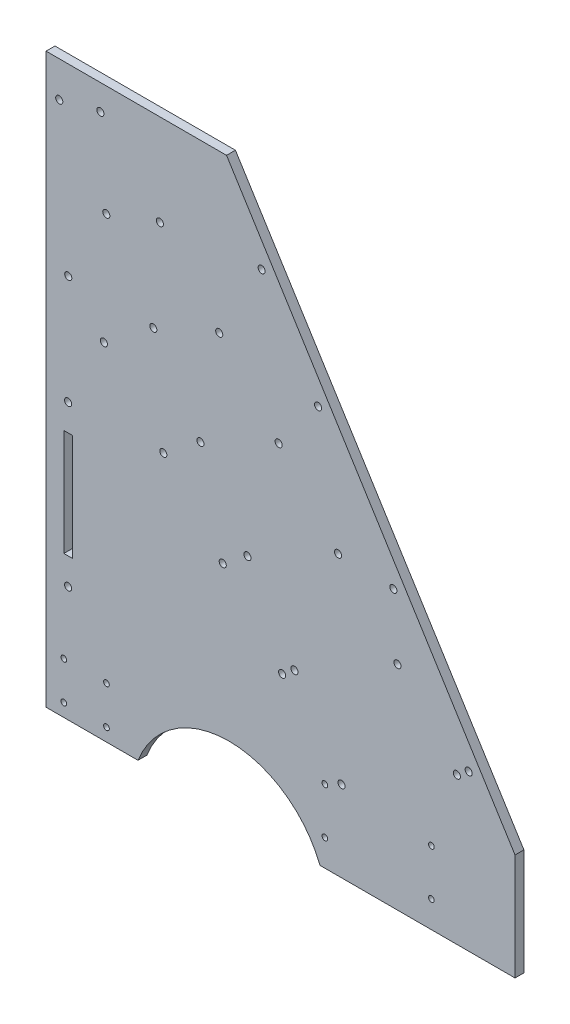
from build123d import *

# Parameters (mm, degrees)
SKETCH1_W           = 381.36114963
SKETCH1_H           = 320
BOSS_EXTRUDE1_DEPTH = 5
SKETCH2_R           = 55
CUT_EXTRUDE1_DEPTH  = 5
CUT_EXTRUDE2_DEPTH  = 5
SKETCH6_R           = 1.6
CUT_EXTRUDE5_DEPTH  = 5
CUT_EXTRUDE6_DEPTH  = 10
SKETCH4_R           = 1.6
CUT_EXTRUDE7_DEPTH  = 10
CUT_EXTRUDE8_DEPTH  = 31.5
SKETCH9_R           = 2
CUT_EXTRUDE9_DEPTH  = 10
CUT_EXTRUDE10_DEPTH = 10
CUT_EXTRUDE11_DEPTH = 10
SKETCH14_W          = 4.8
SKETCH14_H          = 60
CUT_EXTRUDE12_DEPTH = 5
SKETCH15_R          = 2
CUT_EXTRUDE13_DEPTH = 5


with BuildPart() as part:
    # Sketch1 → Boss-Extrude1 (new body)
    with BuildSketch(Plane.XY):
        with Locations((190.680574815, 160)):
            Rectangle(SKETCH1_W, SKETCH1_H)
    extrude(amount=BOSS_EXTRUDE1_DEPTH)

    # Sketch2 → Cut-Extrude1 (cut)
    with BuildSketch(Plane.XY.offset(5)):
        with Locations((103, -20)):
            Circle(SKETCH2_R)
    extrude(amount=-CUT_EXTRUDE1_DEPTH, mode=Mode.SUBTRACT)

    # Sketch3 → Cut-Extrude2 (cut)
    with BuildSketch(Plane.XY.offset(5)):
        with BuildLine():
            ThreePointArc((120.330565639, 275.917926616), (119.694307975, 273.161991895), (122.450242696, 272.525734232))
            Line((122.450242696, 272.525734232), (120.330565639, 275.917926616))
        make_face()
        with BuildLine():
            Line((120.330565639, 275.917926616), (122.450242696, 272.525734232))
            ThreePointArc((122.450242696, 272.525734232), (123.139643582, 273.252211183), (123.390404167, 274.221830424))
            ThreePointArc((123.390404167, 274.221830424), (122.360023408, 275.971069838), (120.330565639, 275.917926616))
        make_face()
        with BuildLine():
            ThreePointArc((152.125721493, 225.035040847), (151.489463829, 222.279106126), (154.24539855, 221.642848462))
            Line((154.24539855, 221.642848462), (152.125721493, 225.035040847))
        make_face()
        with BuildLine():
            Line((152.125721493, 225.035040847), (154.24539855, 221.642848462))
            ThreePointArc((154.24539855, 221.642848462), (154.934799436, 222.369325414), (155.185560021, 223.338944654))
            ThreePointArc((155.185560021, 223.338944654), (154.155179262, 225.088184069), (152.125721493, 225.035040847))
        make_face()
        with BuildLine():
            ThreePointArc((194.519262632, 157.191193154), (193.883004968, 154.435258433), (196.638939688, 153.79900077))
            Line((196.638939688, 153.79900077), (194.519262632, 157.191193154))
        make_face()
        with BuildLine():
            Line((194.519262632, 157.191193154), (196.638939688, 153.79900077))
            ThreePointArc((196.638939688, 153.79900077), (197.328340574, 154.525477721), (197.57910116, 155.495096962))
            ThreePointArc((197.57910116, 155.495096962), (196.5487204, 157.244336376), (194.519262632, 157.191193154))
        make_face()
        with BuildLine():
            ThreePointArc((236.91280377, 89.347345462), (236.276546106, 86.591410741), (239.032480827, 85.955153077))
            Line((239.032480827, 85.955153077), (236.91280377, 89.347345462))
        make_face()
        with BuildLine():
            Line((236.91280377, 89.347345462), (239.032480827, 85.955153077))
            ThreePointArc((239.032480827, 85.955153077), (239.721881713, 86.681630029), (239.972642299, 87.651249269))
            ThreePointArc((239.972642299, 87.651249269), (238.942261539, 89.400488684), (236.91280377, 89.347345462))
        make_face()
        with BuildLine():
            ThreePointArc((268.707959624, 38.464459692), (268.07170196, 35.708524972), (270.827636681, 35.072267308))
            Line((270.827636681, 35.072267308), (268.707959624, 38.464459692))
        make_face()
        with BuildLine():
            Line((268.707959624, 38.464459692), (270.827636681, 35.072267308))
            ThreePointArc((270.827636681, 35.072267308), (271.517037567, 35.79874426), (271.767798153, 36.7683635))
            ThreePointArc((271.767798153, 36.7683635), (270.737417393, 38.517602914), (268.707959624, 38.464459692))
        make_face()
        with BuildLine():
            ThreePointArc((300.503115478, -12.418426077), (299.866857814, -15.174360798), (302.622792535, -15.810618462))
            Line((302.622792535, -15.810618462), (300.503115478, -12.418426077))
        make_face()
        with BuildLine():
            Line((300.503115478, -12.418426077), (302.622792535, -15.810618462))
            ThreePointArc((302.622792535, -15.810618462), (303.312193421, -15.08414151), (303.562954007, -14.114522269))
            ThreePointArc((303.562954007, -14.114522269), (302.532573247, -12.365282855), (300.503115478, -12.418426077))
        make_face()
    extrude(amount=-CUT_EXTRUDE2_DEPTH, mode=Mode.SUBTRACT)

    # Sketch6 → Cut-Extrude5 (cut)
    with BuildSketch(Plane.XY.offset(5)):
        with Locations((10, 28.7)):
            Circle(SKETCH6_R)
        with Locations((34, 28.7)):
            Circle(SKETCH6_R)
        with Locations((10, 7.3)):
            Circle(SKETCH6_R)
        with Locations((34, 7.3)):
            Circle(SKETCH6_R)
        with Locations((310, 28.7)):
            Circle(SKETCH6_R)
        with Locations((334, 28.7)):
            Circle(SKETCH6_R)
        with Locations((334, 7.3)):
            Circle(SKETCH6_R)
        with Locations((310, 7.3)):
            Circle(SKETCH6_R)
    extrude(amount=-CUT_EXTRUDE5_DEPTH, mode=Mode.SUBTRACT)

    # Sketch7 → Cut-Extrude6 (cut)
    with BuildSketch(Plane.XY.offset(5)):
        Polygon((101.628867038, 320), (264.094898534, 60), (381.36114963, 60), (381.36114963, 320), align=None)
    extrude(amount=-CUT_EXTRUDE6_DEPTH, mode=Mode.SUBTRACT)

    # Sketch4 → Cut-Extrude7 (cut)
    with BuildSketch(Plane(origin=(0, 0, 0), x_dir=(-1, 0, 0), z_dir=(0, 0, -1))):
        with Locations((-157, 41)):
            Circle(SKETCH4_R)
        with Locations((-157, 15)):
            Circle(SKETCH4_R)
        with Locations((-217, 15)):
            Circle(SKETCH4_R)
        with Locations((-217, 41)):
            Circle(SKETCH4_R)
    extrude(amount=-CUT_EXTRUDE7_DEPTH, mode=Mode.SUBTRACT)

    # Sketch8 → Cut-Extrude8 (cut)
    with BuildSketch(Plane.XY.offset(5)):
        Polygon((-627.043699354, 0), (212.766195579, 0), (381.36114963, 0), (381.36114963, 89.759390224), (264.094898534, 89.759390224), (264.094898534, 60), (264.094898534, 0), (264.094898534, -839.809894932), (1416.040479004, 382.541943999), (524.901881116, 1222.351838932), align=None)
    extrude(amount=-CUT_EXTRUDE8_DEPTH, mode=Mode.SUBTRACT)

    # Sketch9 → Cut-Extrude9 (cut)
    with BuildSketch(Plane.XY.offset(5)):
        with Locations((7.410608572, 300)):
            Circle(SKETCH9_R)
        with Locations((33.906571783, 257.597595192)):
            Circle(SKETCH9_R)
        with Locations((60.402534995, 215.195190384)):
            Circle(SKETCH9_R)
        with Locations((86.898498207, 172.792785577)):
            Circle(SKETCH9_R)
        with Locations((113.394461418, 130.390380769)):
            Circle(SKETCH9_R)
        with Locations((139.89042463, 87.987975961)):
            Circle(SKETCH9_R)
        with Locations((166.386387842, 45.585571153)):
            Circle(SKETCH9_R)
    extrude(amount=-CUT_EXTRUDE9_DEPTH, mode=Mode.SUBTRACT)

    # Sketch10 → Cut-Extrude10 (cut)
    with BuildSketch(Plane.XY.offset(5)):
        with BuildLine():
            ThreePointArc((11.148087167, 217.995170664), (11.000058728, 215.1706198), (13.824609592, 215.022591362))
            Line((13.824609592, 215.022591362), (11.148087167, 217.995170664))
        make_face()
        with BuildLine():
            Line((11.148087167, 217.995170664), (13.824609592, 215.022591362))
            ThreePointArc((13.824609592, 215.022591362), (14.313439295, 215.695407727), (14.486348379, 216.508881013))
            ThreePointArc((14.486348379, 216.508881013), (13.299821665, 218.335971928), (11.148087167, 217.995170664))
        make_face()
        with BuildLine():
            ThreePointArc((31.222005357, 195.7008259), (31.073976919, 192.876275036), (33.898527783, 192.728246598))
            Line((33.898527783, 192.728246598), (31.222005357, 195.7008259))
        make_face()
        with BuildLine():
            Line((31.222005357, 195.7008259), (33.898527783, 192.728246598))
            ThreePointArc((33.898527783, 192.728246598), (34.387357485, 193.401062962), (34.56026657, 194.214536249))
            ThreePointArc((34.56026657, 194.214536249), (33.373739856, 196.041627164), (31.222005357, 195.7008259))
        make_face()
        with BuildLine():
            ThreePointArc((64.678535675, 158.543584626), (64.530507237, 155.719033762), (67.355058101, 155.571005324))
            Line((67.355058101, 155.571005324), (64.678535675, 158.543584626))
        make_face()
        with BuildLine():
            Line((64.678535675, 158.543584626), (67.355058101, 155.571005324))
            ThreePointArc((67.355058101, 155.571005324), (67.843887803, 156.243821689), (68.016796888, 157.057294975))
            ThreePointArc((68.016796888, 157.057294975), (66.830270174, 158.88438589), (64.678535675, 158.543584626))
        make_face()
        with BuildLine():
            ThreePointArc((98.135065993, 121.386343352), (97.987037555, 118.561792488), (100.811588419, 118.41376405))
            Line((100.811588419, 118.41376405), (98.135065993, 121.386343352))
        make_face()
        with BuildLine():
            Line((98.135065993, 121.386343352), (100.811588419, 118.41376405))
            ThreePointArc((100.811588419, 118.41376405), (101.300418121, 119.086580415), (101.473327206, 119.900053701))
            ThreePointArc((101.473327206, 119.900053701), (100.286800492, 121.727144616), (98.135065993, 121.386343352))
        make_face()
        with BuildLine():
            ThreePointArc((131.591596311, 84.229102078), (131.443567873, 81.404551214), (134.268118737, 81.256522776))
            Line((134.268118737, 81.256522776), (131.591596311, 84.229102078))
        make_face()
        with BuildLine():
            Line((131.591596311, 84.229102078), (134.268118737, 81.256522776))
            ThreePointArc((134.268118737, 81.256522776), (134.756948439, 81.929339141), (134.929857524, 82.742812427))
            ThreePointArc((134.929857524, 82.742812427), (133.74333081, 84.569903342), (131.591596311, 84.229102078))
        make_face()
    extrude(amount=-CUT_EXTRUDE10_DEPTH, mode=Mode.SUBTRACT)

    # Sketch12 → Cut-Extrude11 (cut)
    with BuildSketch(Plane.XY.offset(5)):
        with BuildLine():
            ThreePointArc((29.259303801, 307.172549721), (29.111275363, 304.347998857), (31.935826227, 304.199970419))
            Line((31.935826227, 304.199970419), (29.259303801, 307.172549721))
        make_face()
        with BuildLine():
            Line((29.259303801, 307.172549721), (31.935826227, 304.199970419))
            ThreePointArc((31.935826227, 304.199970419), (32.424655929, 304.872786784), (32.597565014, 305.68626007))
            ThreePointArc((32.597565014, 305.68626007), (31.4110383, 307.513350985), (29.259303801, 307.172549721))
        make_face()
        with BuildLine():
            ThreePointArc((62.715834119, 270.015308447), (62.567805681, 267.190757584), (65.392356545, 267.042729145))
            Line((65.392356545, 267.042729145), (62.715834119, 270.015308447))
        make_face()
        with BuildLine():
            Line((62.715834119, 270.015308447), (65.392356545, 267.042729145))
            ThreePointArc((65.392356545, 267.042729145), (65.881186247, 267.71554551), (66.054095332, 268.529018796))
            ThreePointArc((66.054095332, 268.529018796), (64.867568618, 270.356109712), (62.715834119, 270.015308447))
        make_face()
        with BuildLine():
            ThreePointArc((96.172364437, 232.858067173), (96.024335999, 230.03351631), (98.848886863, 229.885487871))
            Line((98.848886863, 229.885487871), (96.172364437, 232.858067173))
        make_face()
        with BuildLine():
            Line((96.172364437, 232.858067173), (98.848886863, 229.885487871))
            ThreePointArc((98.848886863, 229.885487871), (99.337716565, 230.558304236), (99.51062565, 231.371777522))
            ThreePointArc((99.51062565, 231.371777522), (98.324098936, 233.198868438), (96.172364437, 232.858067173))
        make_face()
        with BuildLine():
            ThreePointArc((129.628894755, 195.7008259), (129.480866317, 192.876275036), (132.305417181, 192.728246598))
            Line((132.305417181, 192.728246598), (129.628894755, 195.7008259))
        make_face()
        with BuildLine():
            Line((129.628894755, 195.7008259), (132.305417181, 192.728246598))
            ThreePointArc((132.305417181, 192.728246598), (132.794246883, 193.401062962), (132.967155968, 194.214536249))
            ThreePointArc((132.967155968, 194.214536249), (131.780629254, 196.041627164), (129.628894755, 195.7008259))
        make_face()
        with BuildLine():
            ThreePointArc((163.085425073, 158.543584626), (162.937396635, 155.719033762), (165.761947499, 155.571005324))
            Line((165.761947499, 155.571005324), (163.085425073, 158.543584626))
        make_face()
        with BuildLine():
            Line((163.085425073, 158.543584626), (165.761947499, 155.571005324))
            ThreePointArc((165.761947499, 155.571005324), (166.250777201, 156.243821689), (166.423686286, 157.057294975))
            ThreePointArc((166.423686286, 157.057294975), (165.237159572, 158.88438589), (163.085425073, 158.543584626))
        make_face()
        with BuildLine():
            ThreePointArc((196.541955391, 121.386343352), (196.393926953, 118.561792488), (199.218477817, 118.41376405))
            Line((199.218477817, 118.41376405), (196.541955391, 121.386343352))
        make_face()
        with BuildLine():
            Line((196.541955391, 121.386343352), (199.218477817, 118.41376405))
            ThreePointArc((199.218477817, 118.41376405), (199.707307519, 119.086580415), (199.880216604, 119.900053701))
            ThreePointArc((199.880216604, 119.900053701), (198.69368989, 121.727144616), (196.541955391, 121.386343352))
        make_face()
        with BuildLine():
            ThreePointArc((229.998485709, 84.229102078), (229.850457271, 81.404551214), (232.675008134, 81.256522776))
            Line((232.675008134, 81.256522776), (229.998485709, 84.229102078))
        make_face()
        with BuildLine():
            Line((229.998485709, 84.229102078), (232.675008134, 81.256522776))
            ThreePointArc((232.675008134, 81.256522776), (233.163837837, 81.929339141), (233.336746922, 82.742812427))
            ThreePointArc((233.336746922, 82.742812427), (232.150220208, 84.569903342), (229.998485709, 84.229102078))
        make_face()
    extrude(amount=-CUT_EXTRUDE11_DEPTH, mode=Mode.SUBTRACT)

    # Sketch14 → Cut-Extrude12 (cut)
    with BuildSketch(Plane.XY.offset(5)):
        with Locations((12.4, 110)):
            Rectangle(SKETCH14_W, SKETCH14_H)
    extrude(amount=-CUT_EXTRUDE12_DEPTH, mode=Mode.SUBTRACT)

    # Sketch15 → Cut-Extrude13 (cut)
    with BuildSketch(Plane.XY.offset(5)):
        with Locations((12.4, 155)):
            Circle(SKETCH15_R)
        with Locations((12.4, 65)):
            Circle(SKETCH15_R)
    extrude(amount=-CUT_EXTRUDE13_DEPTH, mode=Mode.SUBTRACT)


solid = part.part
